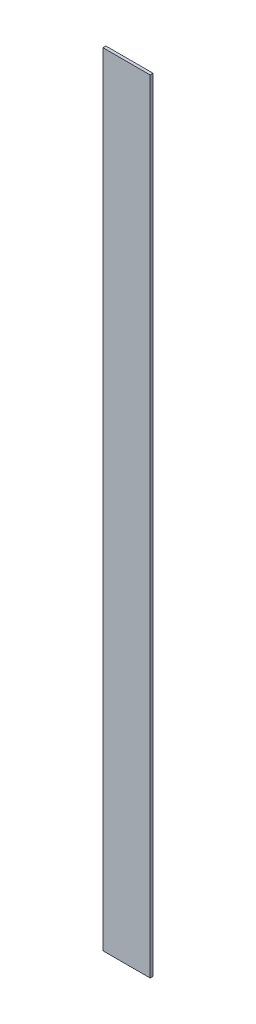
from build123d import *

# Parameters (mm, degrees)
SKETCH1_W           = 50.8
SKETCH1_H           = 843.026
BOSS_EXTRUDE1_DEPTH = 3.175


with BuildPart() as part:
    # Sketch1 → Boss-Extrude1 (new body)
    with BuildSketch(Plane.XY):
        with Locations((-6.976901453, -396.395867687)):
            Rectangle(SKETCH1_W, SKETCH1_H)
    extrude(amount=BOSS_EXTRUDE1_DEPTH)


solid = part.part
